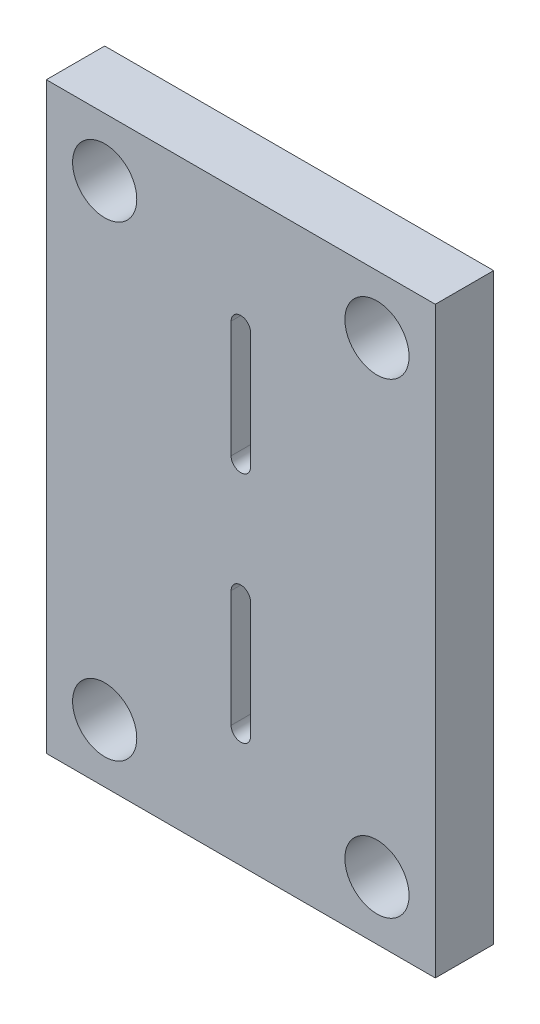
from build123d import *

# Parameters (mm, degrees)
CROQUIS1_W              = 20
CROQUIS1_H              = 30
CROQUIS1_R              = 1.65
SALIENTE_EXTRUIR1_DEPTH = 3
CORTAR_EXTRUIR1_REACH   = 5


with BuildPart() as part:
    # Croquis1 → Saliente-Extruir1 (new body)
    with BuildSketch(Plane.XY):
        Rectangle(CROQUIS1_W, CROQUIS1_H)
        with Locations((-7, 12)):
            Circle(CROQUIS1_R, mode=Mode.SUBTRACT)
        with Locations((7, 12)):
            Circle(CROQUIS1_R, mode=Mode.SUBTRACT)
        with Locations((7, -12)):
            Circle(CROQUIS1_R, mode=Mode.SUBTRACT)
        with Locations((-7, -12)):
            Circle(CROQUIS1_R, mode=Mode.SUBTRACT)
    extrude(amount=SALIENTE_EXTRUIR1_DEPTH)

    # Croquis2 → Cortar-Extruir1 (cut, up to next)
    with BuildSketch(Plane.XY.offset(3), mode=Mode.PRIVATE) as cortar_extruir1_sk1:
        with BuildLine():
            Line((-0.5, -9), (-0.5, -3))
            ThreePointArc((-0.5, -3), (0, -2.5), (0.5, -3))
            Line((0.5, -3), (0.5, -9))
            ThreePointArc((0.5, -9), (0, -9.5), (-0.5, -9))
        make_face()
    cortar_extruir1_tool1 = extrude(cortar_extruir1_sk1.sketch, amount=-CORTAR_EXTRUIR1_REACH, mode=Mode.PRIVATE) & part.part
    add(cortar_extruir1_tool1.solids().sort_by_distance((0, -6, 3))[0], mode=Mode.SUBTRACT)
    # Croquis2 → Cortar-Extruir1 (cut, up to next)
    with BuildSketch(Plane.XY.offset(3), mode=Mode.PRIVATE) as cortar_extruir1_sk2:
        with BuildLine():
            Line((-0.5, 3), (-0.5, 9))
            ThreePointArc((-0.5, 9), (0, 9.5), (0.5, 9))
            Line((0.5, 9), (0.5, 3))
            ThreePointArc((0.5, 3), (0, 2.5), (-0.5, 3))
        make_face()
    cortar_extruir1_tool2 = extrude(cortar_extruir1_sk2.sketch, amount=-CORTAR_EXTRUIR1_REACH, mode=Mode.PRIVATE) & part.part
    add(cortar_extruir1_tool2.solids().sort_by_distance((0, 6, 3))[0], mode=Mode.SUBTRACT)


solid = part.part
